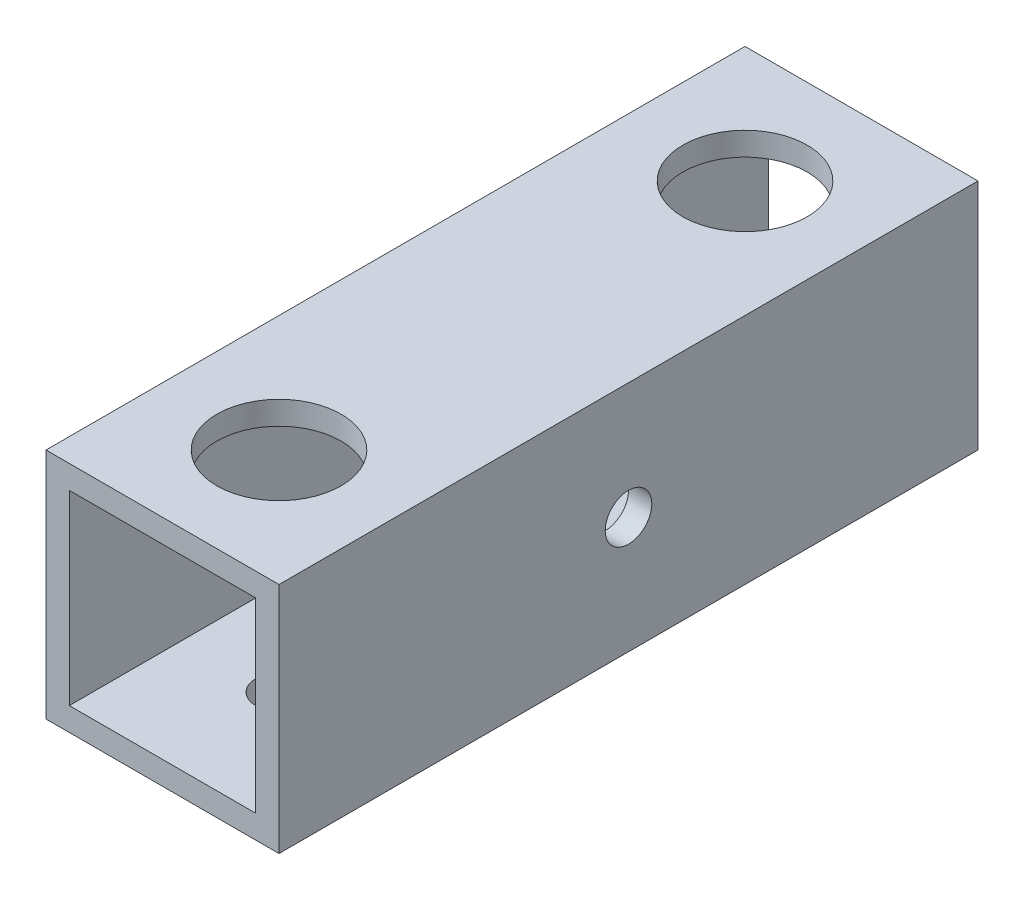
from build123d import *

# Parameters (mm, degrees)
SKETCH_1_W          = 15
SKETCH_1_H          = 15
SKETCH_1_W_2        = 12
SKETCH_1_H_2        = 12
EXTRUDE_2_DEPTH     = 45
SKETCH_2_R          = 1.5
CUT_EXTRUDE_1_DEPTH = 10
SKETCH_3_R          = 1.5
CUT_EXTRUDE_2_DEPTH = 10
SKETCH_4_R          = 4
CUT_EXTRUDE_3_DEPTH = 10
SKETCH_5_R          = 4
CUT_EXTRUDE_4_DEPTH = 10


with BuildPart() as part:
    # ｽｹｯﾁ1 → ﾎﾞｽ - 押し出し2 (new body)
    with BuildSketch(Plane.XY):
        with Locations((0.489915859, 0.232626086)):
            Rectangle(SKETCH_1_W, SKETCH_1_H)
        with Locations((0.489915859, 0.232626086)):
            Rectangle(SKETCH_1_W_2, SKETCH_1_H_2, mode=Mode.SUBTRACT)
    extrude(amount=EXTRUDE_2_DEPTH)

    # ｽｹｯﾁ2 → ｶｯﾄ - 押し出し1 (cut)
    with BuildSketch(Plane(origin=(7.989915859, 0, 0), x_dir=(0, 0, -1), z_dir=(1, 0, 0))):
        with Locations((-22.5, 0.232626086)):
            Circle(SKETCH_2_R)
    extrude(amount=-CUT_EXTRUDE_1_DEPTH, mode=Mode.SUBTRACT)

    # ｽｹｯﾁ3 → ｶｯﾄ - 押し出し2 (cut)
    with BuildSketch(Plane.XZ.offset(7.267373914)):
        with Locations((0.489915859, 37.5)):
            Circle(SKETCH_3_R)
        with Locations((0.489915859, 7.5)):
            Circle(SKETCH_3_R)
    extrude(amount=-CUT_EXTRUDE_2_DEPTH, mode=Mode.SUBTRACT)

    # ｽｹｯﾁ4 → ｶｯﾄ - 押し出し3 (cut)
    with BuildSketch(Plane.ZY.offset(7.010084141)):
        with Locations((22.5, 0.232626086)):
            Circle(SKETCH_4_R)
    extrude(amount=-CUT_EXTRUDE_3_DEPTH, mode=Mode.SUBTRACT)

    # ｽｹｯﾁ5 → ｶｯﾄ - 押し出し4 (cut)
    with BuildSketch(Plane(origin=(0, 7.732626086, 0), x_dir=(1, 0, 0), z_dir=(0, 1, 0))):
        with Locations((0.489915859, -7.5)):
            Circle(SKETCH_5_R)
        with Locations((0.489915859, -37.5)):
            Circle(SKETCH_5_R)
    extrude(amount=-CUT_EXTRUDE_4_DEPTH, mode=Mode.SUBTRACT)


solid = part.part
